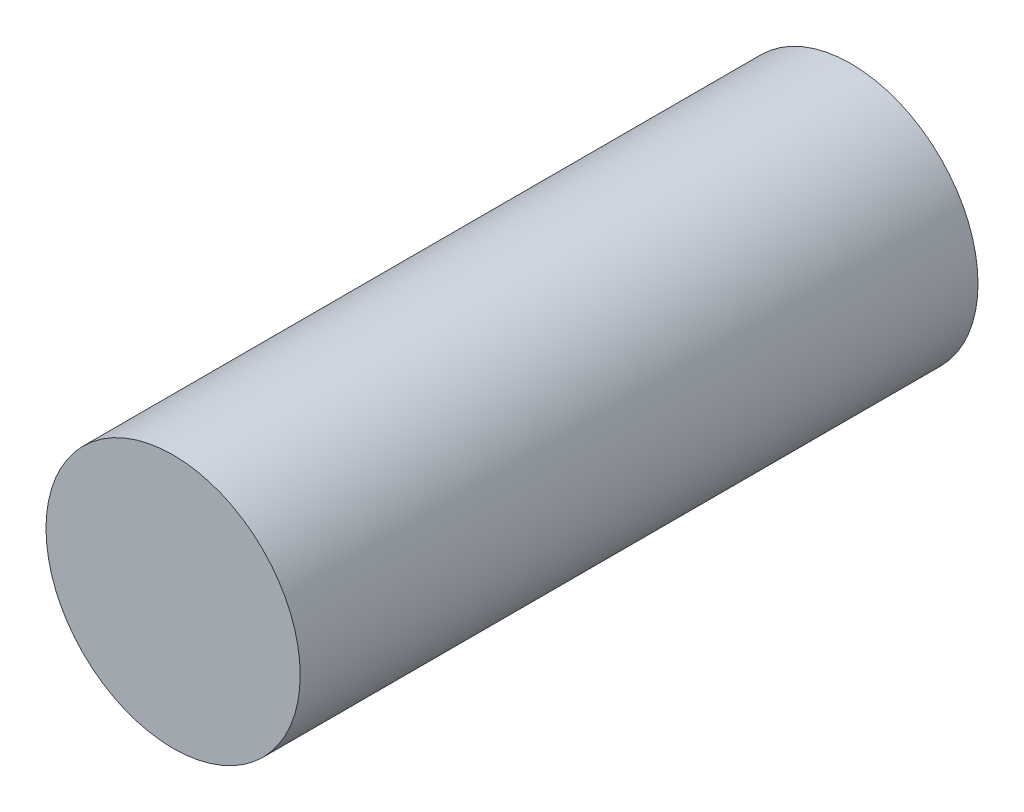
from build123d import *

# Parameters (mm, degrees)
SKETCH_1_R      = 1.5
EXTRUDE_1_DEPTH = 8


with BuildPart() as part:
    # 草图1 → 凸台-拉伸1 (new body)
    with BuildSketch(Plane.XY):
        Circle(SKETCH_1_R)
    extrude(amount=EXTRUDE_1_DEPTH)


solid = part.part
